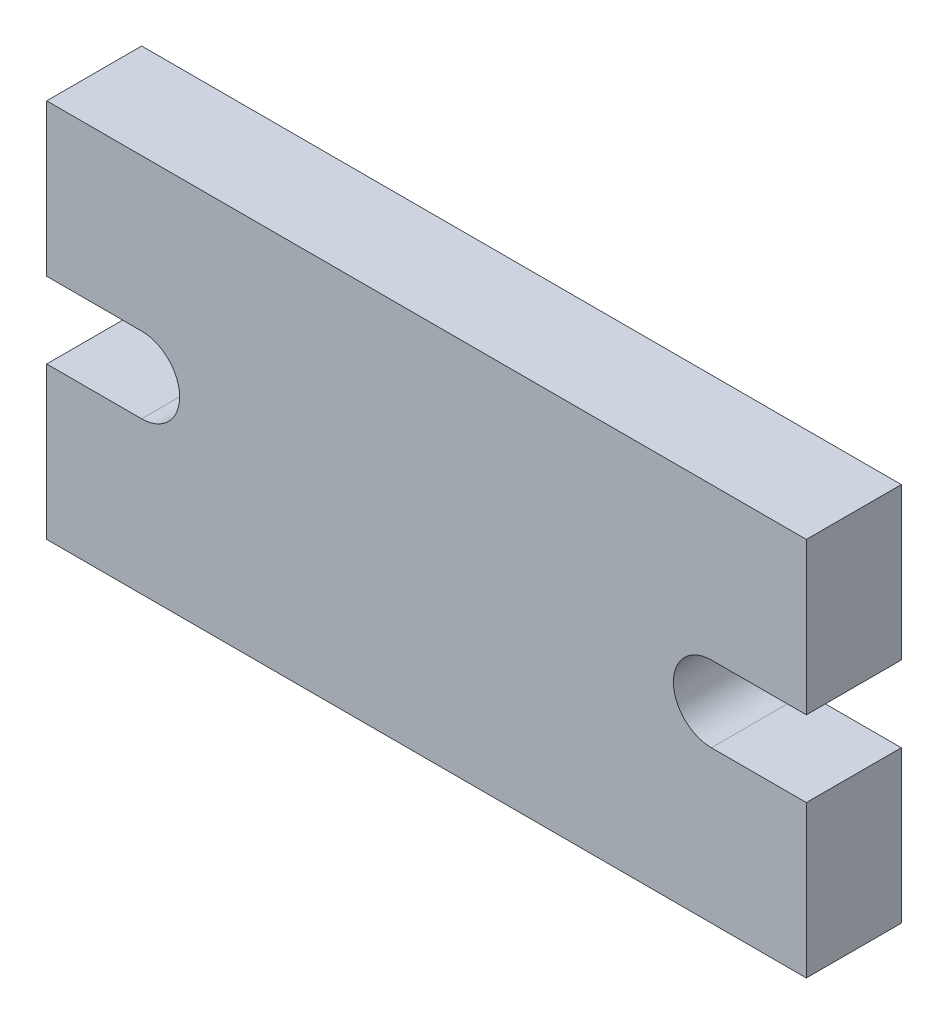
from build123d import *

# Parameters (mm, degrees)
BOSS_EXTRUDE1_DEPTH = 5


with BuildPart() as part:
    # Sketch1 → Boss-Extrude1 (new body)
    with BuildSketch(Plane.XY):
        with BuildLine():
            Line((19.615384615, -0.365384615), (19.615384615, -8.365384615))
            Line((19.615384615, -8.365384615), (-20.384615385, -8.365384615))
            Line((-20.384615385, -8.365384615), (-20.384615385, -0.365384615))
            Line((-20.384615385, -0.365384615), (-15.384615385, -0.365384615))
            ThreePointArc((-15.384615385, -0.365384615), (-13.384615385, 1.634615385), (-15.384615385, 3.634615385))
            Line((-15.384615385, 3.634615385), (-20.384615385, 3.634615385))
            Line((-20.384615385, 3.634615385), (-20.384615385, 11.634615385))
            Line((-20.384615385, 11.634615385), (19.615384615, 11.634615385))
            Line((19.615384615, 11.634615385), (19.615384615, 3.634615385))
            Line((19.615384615, 3.634615385), (14.615384615, 3.634615385))
            ThreePointArc((14.615384615, 3.634615385), (12.615384615, 1.634615385), (14.615384615, -0.365384615))
            Line((14.615384615, -0.365384615), (19.615384615, -0.365384615))
        make_face()
    extrude(amount=BOSS_EXTRUDE1_DEPTH)


solid = part.part
